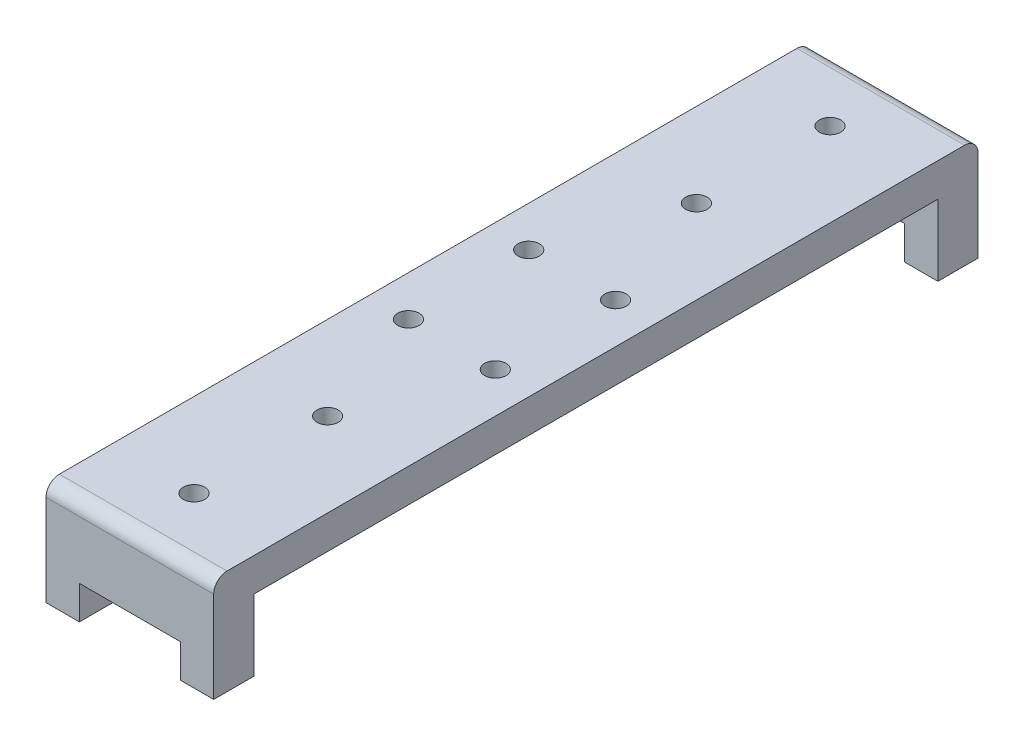
from build123d import *

# Parameters (mm, degrees)
SKETCH2_W           = 25.1
SKETCH2_H           = 57.2
SKETCH2_R           = 1.6
BOSS_EXTRUDE1_DEPTH = 5
BOSS_EXTRUDE2_DEPTH = 6
FILLET1_R           = 2


with BuildPart() as part:
    # Sketch2 → Boss-Extrude1 (new body)
    with BuildSketch(Plane(origin=(0, 0, 0), x_dir=(1, 0, 0), z_dir=(0, 1, 0))):
        with Locations((0, 28.6)):
            Rectangle(SKETCH2_W, SKETCH2_H)
        with Locations((0, 27.6)):
            Circle(SKETCH2_R, mode=Mode.SUBTRACT)
        with Locations((-6.5, 9)):
            Circle(SKETCH2_R, mode=Mode.SUBTRACT)
        with Locations((6.5, 9)):
            Circle(SKETCH2_R, mode=Mode.SUBTRACT)
        with Locations((0, 47.6)):
            Circle(SKETCH2_R, mode=Mode.SUBTRACT)
    boss_extrude1 = extrude(amount=BOSS_EXTRUDE1_DEPTH)

    # Sketch4 → Boss-Extrude2 (add)
    with BuildSketch(Plane(origin=(0, 0, -57.2), x_dir=(-1, 0, 0), z_dir=(0, 0, -1))):
        Polygon((12.55, 0), (-12.55, 0), (-12.55, -10.65), (-7.55, -10.65), (-7.55, -5.65), (7.55, -5.65), (7.55, -10.65), (12.55, -10.65), align=None)
    boss_extrude2 = extrude(amount=-BOSS_EXTRUDE2_DEPTH)

    # Mirror1: Boss-Extrude1, Boss-Extrude2 across plane
    add(boss_extrude1.mirror(Plane.XY))
    add(boss_extrude2.mirror(Plane.XY))

    # Fillet1
    fillet1_edges = [part.edges().sort_by_distance(p)[0] for p in [
        (0, 5, -57.2),
        (0, 5, 57.2),
    ]]
    fillet(fillet1_edges, radius=FILLET1_R)


solid = part.part
